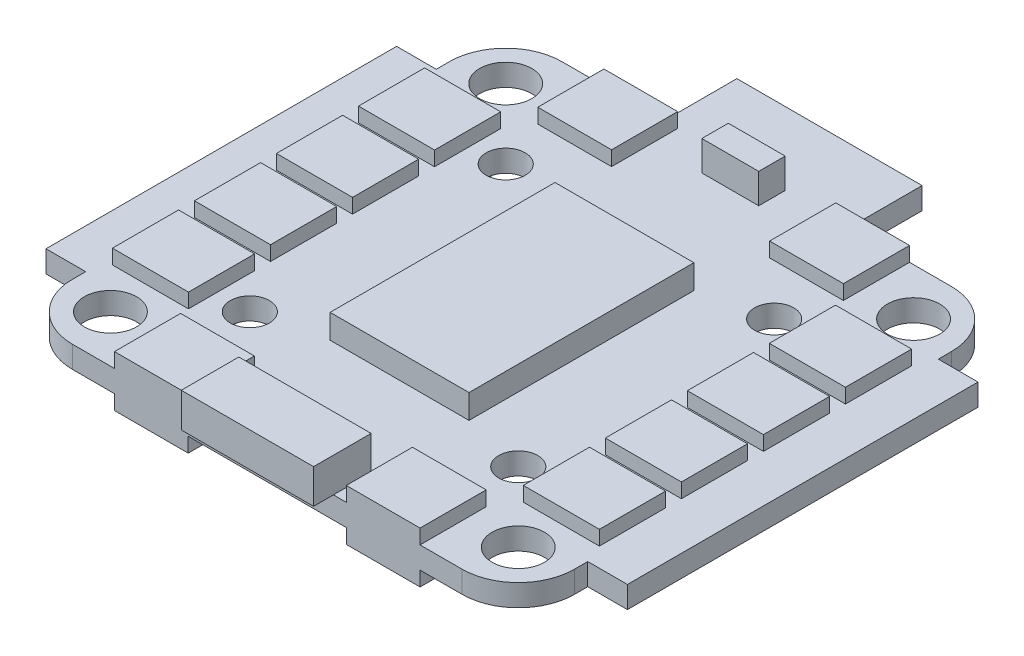
from build123d import *

# Parameters (mm, degrees)
SKETCH1_R                       = 1.975
PCB_DEPTH                       = 0.825
SKETCH7_R                       = 1.475
INNER_HOLES_DEPTH               = 1
INNER_HOLES_DEPTH_BACK          = 2.65
SKETCH8_W                       = 10
SKETCH8_H                       = 4.35
CONNECTOR_DEPTH                 = 2.6
SKETCH9_W                       = 4.3
SKETCH9_H                       = 2
TOP_COMPONENT_DEPTH             = 2.255
SKETCH10_W                      = 5.75
SKETCH10_H                      = 5
SIDE_COMPONENTS_DEPTH           = 1.1
SKETCH11_W                      = 10.5
SKETCH11_H                      = 17
CENTRAL_COMPONENTS_DEPTH        = 1.825
SKETCH12_W                      = 5.575
SKETCH12_H                      = 5
TOP_AND_BOTTOM_COMPONENTS_DEPTH = 1.105


with BuildPart() as part:
    # Sketch1 → PCB (new body, symmetric)
    with BuildSketch(Plane(origin=(0, 0, 0), x_dir=(1, 0, 0), z_dir=(0, 1, 0))):
        with BuildLine():
            Line((-7, 42.5), (7, 42.5))
            Line((7, 42.5), (7, 37))
            Line((7, 37), (14.725, 37))
            ThreePointArc((14.725, 37), (17.73020382, 35.75520382), (18.975, 32.75))
            Line((18.975, 32.75), (18.975, 31.75))
            Line((18.975, 31.75), (21.975, 31.75))
            Line((21.975, 31.75), (21.975, 5.25))
            Line((21.975, 5.25), (18.975, 5.25))
            Line((18.975, 5.25), (18.975, 4.25))
            ThreePointArc((18.975, 4.25), (17.73020382, 1.24479618), (14.725, 0))
            Line((14.725, 0), (-14.725, 0))
            ThreePointArc((-14.725, 0), (-17.73020382, 1.24479618), (-18.975, 4.25))
            Line((-18.975, 4.25), (-18.975, 5.25))
            Line((-18.975, 5.25), (-21.975, 5.25))
            Line((-21.975, 5.25), (-21.975, 31.75))
            Line((-21.975, 31.75), (-18.975, 31.75))
            Line((-18.975, 31.75), (-18.975, 32.75))
            ThreePointArc((-18.975, 32.75), (-17.73020382, 35.75520382), (-14.725, 37))
            Line((-14.725, 37), (-7, 37))
            Line((-7, 37), (-7, 42.5))
        make_face()
        with Locations((15.414429112, 33.439429112)):
            Circle(SKETCH1_R, mode=Mode.SUBTRACT)
        with Locations((15.414429112, 3.560570888)):
            Circle(SKETCH1_R, mode=Mode.SUBTRACT)
        with Locations((-15.414429112, 3.560570888)):
            Circle(SKETCH1_R, mode=Mode.SUBTRACT)
        with Locations((-15.414429112, 33.439429112)):
            Circle(SKETCH1_R, mode=Mode.SUBTRACT)
    extrude(amount=PCB_DEPTH, both=True)

    # Sketch7 → inner holes (cut, two sides)
    with BuildSketch(Plane(origin=(0, 0.825, 0), x_dir=(1, 0, 0), z_dir=(0, 1, 0))) as inner_holes_sk:
        with Locations((10.146483592, 28.171483592)):
            Circle(SKETCH7_R)
        with Locations((-10.146483592, 28.171483592)):
            Circle(SKETCH7_R)
        with Locations((-10.146483592, 8.828516408)):
            Circle(SKETCH7_R)
        with Locations((10.146483592, 8.828516408)):
            Circle(SKETCH7_R)
    extrude(amount=INNER_HOLES_DEPTH, mode=Mode.SUBTRACT)
    extrude(inner_holes_sk.sketch, amount=-INNER_HOLES_DEPTH_BACK, mode=Mode.SUBTRACT)

    # Sketch8 → Connector (add)
    with BuildSketch(Plane(origin=(0, 0.825, 0), x_dir=(1, 0, 0), z_dir=(0, 1, 0))):
        with Locations((0, 0.675)):
            Rectangle(SKETCH8_W, SKETCH8_H)
    extrude(amount=CONNECTOR_DEPTH)

    # Sketch9 → Top component (add)
    with BuildSketch(Plane(origin=(0, 0.825, 0), x_dir=(1, 0, 0), z_dir=(0, 1, 0))):
        with Locations((0, 36)):
            Rectangle(SKETCH9_W, SKETCH9_H)
    extrude(amount=TOP_COMPONENT_DEPTH)

    # Sketch10 → Side Components (add)
    with BuildSketch(Plane(origin=(0, 0.825, 0), x_dir=(1, 0, 0), z_dir=(0, 1, 0))):
        with Locations((15.53, 15.4)):
            Rectangle(SKETCH10_W, SKETCH10_H)
        with Locations((15.53, 9.2)):
            Rectangle(SKETCH10_W, SKETCH10_H)
        with Locations((15.53, 21.6)):
            Rectangle(SKETCH10_W, SKETCH10_H)
        with Locations((15.53, 27.8)):
            Rectangle(SKETCH10_W, SKETCH10_H)
        with Locations((-15.53, 9.2)):
            Rectangle(SKETCH10_W, SKETCH10_H)
        with Locations((-15.53, 15.4)):
            Rectangle(SKETCH10_W, SKETCH10_H)
        with Locations((-15.53, 21.6)):
            Rectangle(SKETCH10_W, SKETCH10_H)
        with Locations((-15.53, 27.8)):
            Rectangle(SKETCH10_W, SKETCH10_H)
    side_components = extrude(amount=SIDE_COMPONENTS_DEPTH)

    # Sketch11 → Central components (add)
    with BuildSketch(Plane(origin=(0, 0.825, 0), x_dir=(1, 0, 0), z_dir=(0, 1, 0))):
        with Locations((0, 18.5)):
            Rectangle(SKETCH11_W, SKETCH11_H)
    extrude(amount=CENTRAL_COMPONENTS_DEPTH)

    # Sketch12 → Top and bottom components (add)
    with BuildSketch(Plane(origin=(0, 0.825, 0), x_dir=(1, 0, 0), z_dir=(0, 1, 0))):
        with Locations((8.7625, 34.5)):
            Rectangle(SKETCH12_W, SKETCH12_H)
        with Locations((8.7625, 2.5)):
            Rectangle(SKETCH12_W, SKETCH12_H)
        with Locations((-8.7625, 2.5)):
            Rectangle(SKETCH12_W, SKETCH12_H)
        with Locations((-8.7625, 34.5)):
            Rectangle(SKETCH12_W, SKETCH12_H)
    top_and_bottom_components = extrude(amount=TOP_AND_BOTTOM_COMPONENTS_DEPTH)

    # Mirror2: Side Components, Top and bottom components across plane
    add(side_components.mirror(Plane.ZX))
    add(top_and_bottom_components.mirror(Plane.ZX))


solid = part.part
